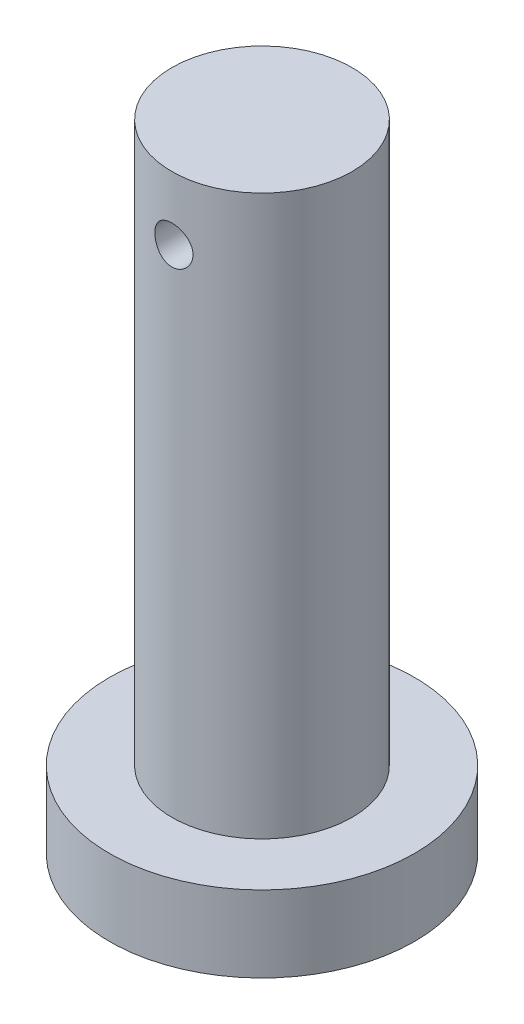
from build123d import *

# Parameters (mm, degrees)
SKETCH3_R               = 3.75
CUT_EXTRUDE1_DEPTH      = 31
CUT_EXTRUDE1_DEPTH_BACK = 31


with BuildPart() as part:
    # Sketch2 → Revolve1 (revolve)
    with BuildSketch(Plane.XY):
        Polygon((0, 0), (30, 0), (30, 15), (17.7222, 15), (17.7222, 125), (0, 125), align=None)
    revolve(axis=Axis((0, 125, 0), (0, -1, 0)))

    # Sketch3 → Cut-Extrude1 (cut, two sides)
    with BuildSketch(Plane.XY) as cut_extrude1_sk:
        with Locations((0, 112.5)):
            Circle(SKETCH3_R)
    extrude(amount=CUT_EXTRUDE1_DEPTH, mode=Mode.SUBTRACT)
    extrude(cut_extrude1_sk.sketch, amount=-CUT_EXTRUDE1_DEPTH_BACK, mode=Mode.SUBTRACT)


solid = part.part
